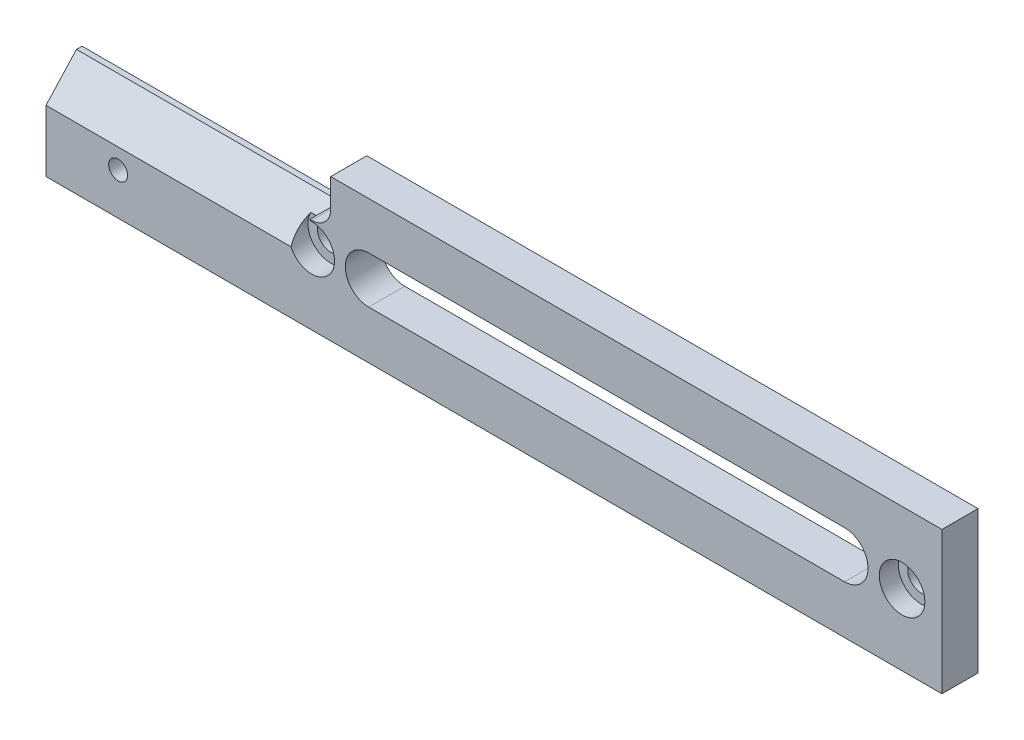
from build123d import *

# Parameters (mm, degrees)
BOSS_EXTRUDE1_DEPTH = 4.826
CUT_EXTRUDE1_DEPTH  = 35.306
SKETCH3_R           = 3.048
CUT_EXTRUDE2_DEPTH  = 2.54
SKETCH4_R           = 1.778
SKETCH4_R_2         = 1.27
CUT_EXTRUDE3_DEPTH  = 5.826
CUT_EXTRUDE4_DEPTH  = 5.826


with BuildPart() as part:
    # Sketch1 → Boss-Extrude1 (new body)
    with BuildSketch(Plane.XY):
        with BuildLine():
            Line((0, 0), (-119.888, 0))
            Line((-119.888, 0), (-119.888, 12.7))
            Line((-119.888, 12.7), (-84.328, 12.7))
            ThreePointArc((-84.328, 12.7), (-82.531948776, 13.443948776), (-81.788, 15.24))
            Line((-81.788, 15.24), (-81.788, 19.05))
            Line((-81.788, 19.05), (0, 19.05))
            Line((0, 19.05), (0, 0))
        make_face()
    extrude(amount=BOSS_EXTRUDE1_DEPTH)

    # Sketch2 → Cut-Extrude1 (cut)
    with BuildSketch(Plane.ZY.offset(119.888)):
        Polygon((0.74979355, 12.7), (4.826, 8.258695089), (4.826, 12.7), align=None)
    extrude(amount=-CUT_EXTRUDE1_DEPTH, mode=Mode.SUBTRACT)

    # Sketch3 → Cut-Extrude2 (cut)
    with BuildSketch(Plane.XY.offset(4.826)):
        with Locations((-5.334, 9.525)):
            Circle(SKETCH3_R)
        with Locations((-84.328, 9.525)):
            Circle(SKETCH3_R)
    extrude(amount=-CUT_EXTRUDE2_DEPTH, mode=Mode.SUBTRACT)

    # Sketch4 → Cut-Extrude3 (cut, through all)
    with BuildSketch(Plane.XY.offset(4.826)):
        with Locations((-5.334, 9.525)):
            Circle(SKETCH4_R)
        with Locations((-84.328, 9.525)):
            Circle(SKETCH4_R)
        with Locations((-110.236, 5.588)):
            Circle(SKETCH4_R_2)
    extrude(amount=-CUT_EXTRUDE3_DEPTH, mode=Mode.SUBTRACT)

    # Sketch5 → Cut-Extrude4 (cut, through all)
    with BuildSketch(Plane.XY.offset(4.826)):
        with BuildLine():
            Line((-76.708, 12.741907021), (-13.0302, 12.741907021))
            ThreePointArc((-13.0302, 12.741907021), (-9.8933, 9.605007021), (-13.0302, 6.468107021))
            Line((-13.0302, 6.468107021), (-76.708, 6.468107021))
            ThreePointArc((-76.708, 6.468107021), (-79.8449, 9.605007021), (-76.708, 12.741907021))
        make_face()
    extrude(amount=-CUT_EXTRUDE4_DEPTH, mode=Mode.SUBTRACT)


solid = part.part
